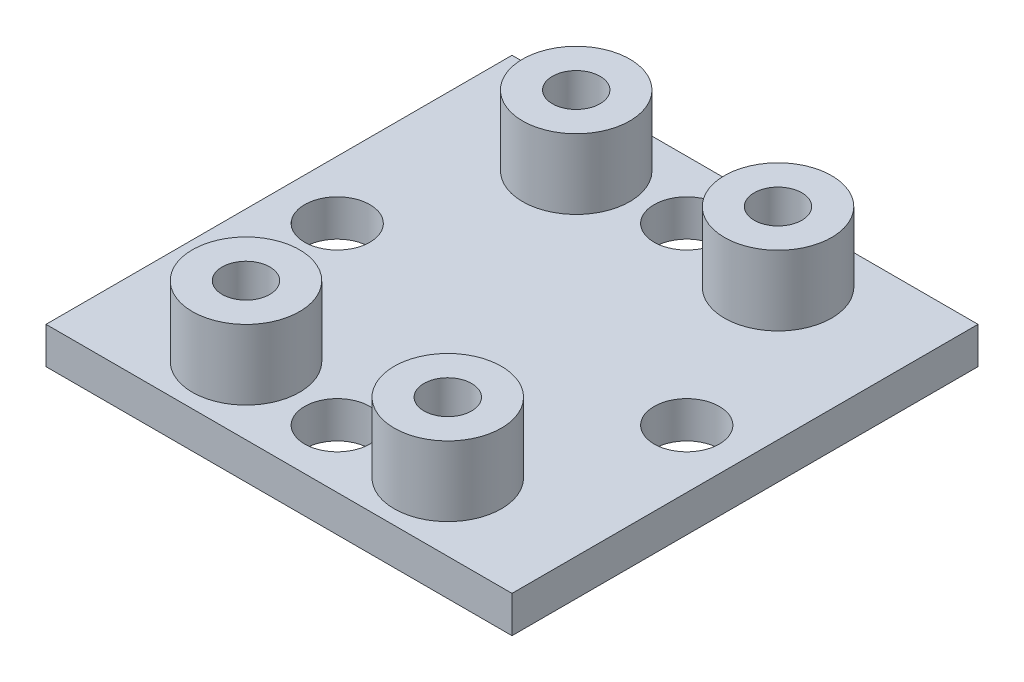
from build123d import *

# Parameters (mm, degrees)
SKETCH1_W           = 25.4
SKETCH1_H           = 25.4
BOSS_EXTRUDE1_DEPTH = 2
SKETCH4_R           = 1.778
CUT_EXTRUDE1_DEPTH  = 3
SKETCH3_R           = 2.921
SKETCH3_R_2         = 1.3
BOSS_EXTRUDE2_DEPTH = 3.81
CIRPATTERN2_COUNT   = 4


with BuildPart() as part:
    # Sketch1 → Boss-Extrude1 (new body)
    with BuildSketch(Plane(origin=(0, 0, 0), x_dir=(1, 0, 0), z_dir=(0, 1, 0))):
        Rectangle(SKETCH1_W, SKETCH1_H)
    extrude(amount=BOSS_EXTRUDE1_DEPTH)

    # Sketch4 → Cut-Extrude1 (cut, through all)
    with BuildSketch(Plane(origin=(0, 0, 0), x_dir=(1, 0, 0), z_dir=(0, 1, 0))):
        with Locations((-9.525, 0)):
            Circle(SKETCH4_R)
    cut_extrude1 = extrude(amount=CUT_EXTRUDE1_DEPTH, mode=Mode.SUBTRACT)

    # Sketch3 → Boss-Extrude2 (add)
    with BuildSketch(Plane(origin=(0, 2, 0), x_dir=(1, 0, 0), z_dir=(0, 1, 0))):
        with Locations((-5.5, 9)):
            Circle(SKETCH3_R)
        with Locations((-5.5, 9)):
            Circle(SKETCH3_R_2, mode=Mode.SUBTRACT)
        with Locations((5.5, 9)):
            Circle(SKETCH3_R)
        with Locations((5.5, 9)):
            Circle(SKETCH3_R_2, mode=Mode.SUBTRACT)
        with Locations((5.5, -9)):
            Circle(SKETCH3_R)
        with Locations((5.5, -9)):
            Circle(SKETCH3_R_2, mode=Mode.SUBTRACT)
        with Locations((-5.5, -9)):
            Circle(SKETCH3_R)
        with Locations((-5.5, -9)):
            Circle(SKETCH3_R_2, mode=Mode.SUBTRACT)
    extrude(amount=BOSS_EXTRUDE2_DEPTH)

    # CirPattern2: Cut-Extrude1 ×4 about axis
    cirpattern2_axis = Axis((0, 0, 0), (0, 1, 0))
    for i in range(1, CIRPATTERN2_COUNT):
        add(cut_extrude1.rotate(cirpattern2_axis, i * 360 / CIRPATTERN2_COUNT), mode=Mode.SUBTRACT)


solid = part.part
